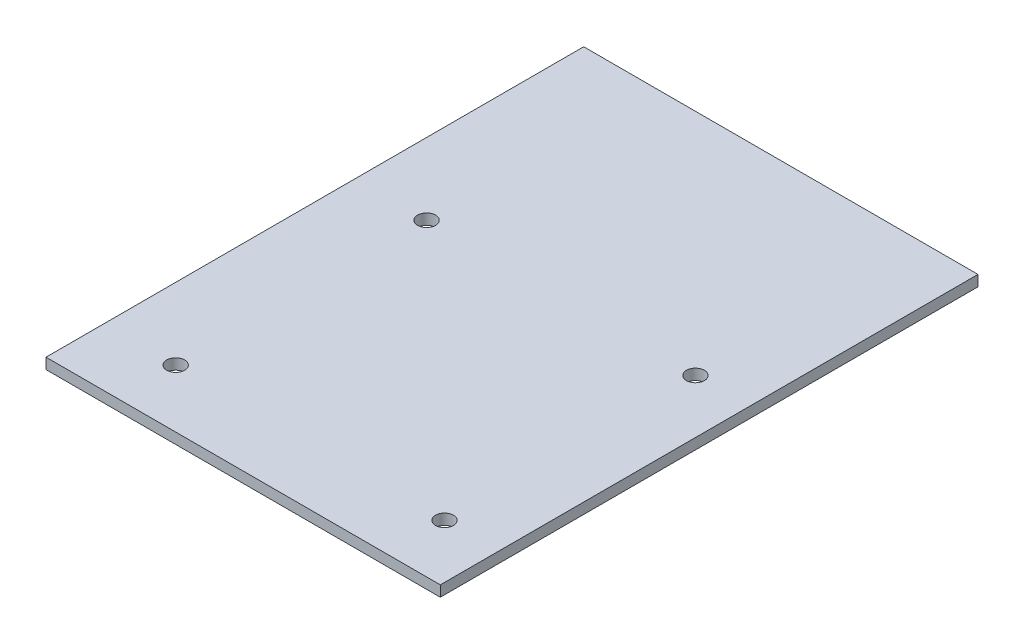
from build123d import *

# Parameters (mm, degrees)
SKETCH1_W                      = 220
SKETCH1_H                      = 300
BOSS_EXTRUDE1_DEPTH            = 6
F_10_0_10_DIAMETER_HOLE1_D     = 10
F_10_0_10_DIAMETER_HOLE1_DEPTH = 11
F_10_0_10_DIAMETER_HOLE1_TIP   = 3.004303095


with BuildPart() as part:
    # Sketch1 → Boss-Extrude1 (new body)
    with BuildSketch(Plane(origin=(0, 0, 0), x_dir=(1, 0, 0), z_dir=(0, 1, 0))):
        Rectangle(SKETCH1_W, SKETCH1_H)
    extrude(amount=BOSS_EXTRUDE1_DEPTH)

    # Ø10.0 (10) Diameter Hole1
    with Locations(Plane.XZ):
        with Locations((-70, 117.650973616), (80, 117.650973616), (80, -22.349026384), (-70, -22.349026384)):
            Hole(F_10_0_10_DIAMETER_HOLE1_D / 2, depth=F_10_0_10_DIAMETER_HOLE1_DEPTH)
            with Locations((0, 0, -(F_10_0_10_DIAMETER_HOLE1_DEPTH + F_10_0_10_DIAMETER_HOLE1_TIP / 2))):  # 118° drill point
                Cone(0, F_10_0_10_DIAMETER_HOLE1_D / 2, F_10_0_10_DIAMETER_HOLE1_TIP, mode=Mode.SUBTRACT)


solid = part.part
